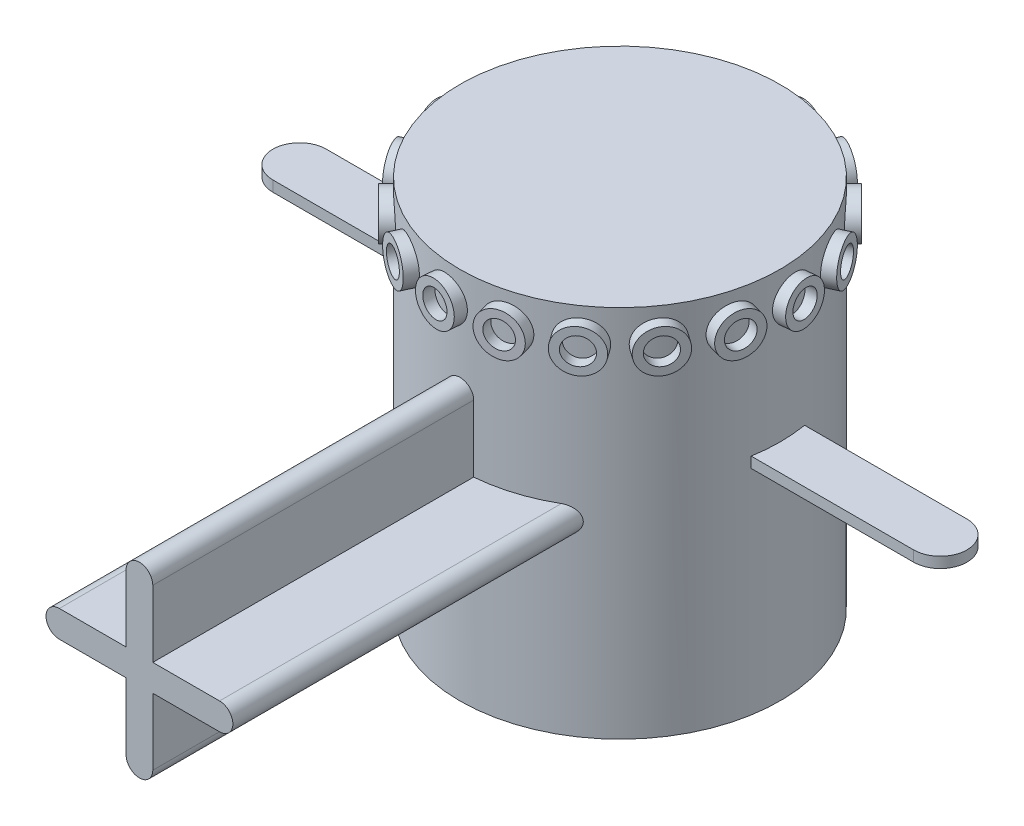
from build123d import *

# Parameters (mm, degrees)
SKETCH2_R           = 38.1
BOSS_EXTRUDE1_DEPTH = 88.9
BOSS_EXTRUDE2_DEPTH = 2.54
BOSS_EXTRUDE3_START = -7.153928
SKETCH4_W           = 6.35
SKETCH4_H           = 6.35
BOSS_EXTRUDE3_DEPTH = 83.353928
BOSS_EXTRUDE4_START = -0.340185
SKETCH6_R           = 5.08
SKETCH6_R_2         = 3.175
BOSS_EXTRUDE4_DEPTH = 2.880185
CIRPATTERN1_COUNT   = 18


with BuildPart() as part:
    # Sketch2 → Boss-Extrude1 (new body)
    with BuildSketch(Plane(origin=(0, 0, 0), x_dir=(1, 0, 0), z_dir=(0, 1, 0))):
        Circle(SKETCH2_R)
    extrude(amount=BOSS_EXTRUDE1_DEPTH)

    # Sketch3 → Boss-Extrude2 (add)
    with BuildSketch(Plane(origin=(0, 50.8, 0), x_dir=(1, 0, 0), z_dir=(0, 1, 0))):
        with BuildLine():
            Line((-76.2, 6.35), (76.2, 6.35))
            ThreePointArc((76.2, 6.35), (82.55, 0), (76.2, -6.35))
            Line((76.2, -6.35), (-76.2, -6.35))
            ThreePointArc((-76.2, -6.35), (-82.55, 0), (-76.2, 6.35))
        make_face()
    extrude(amount=BOSS_EXTRUDE2_DEPTH)

    # Sketch4 → Boss-Extrude3 (add)
    with BuildSketch(Plane.XY.offset(38.1).offset(BOSS_EXTRUDE3_START)):
        with BuildLine():
            Line((-3.175, 63.5), (-3.175, 47.625))
            Line((-3.175, 47.625), (3.175, 47.625))
            Line((3.175, 47.625), (3.175, 63.5))
            ThreePointArc((3.175, 63.5), (0, 66.675), (-3.175, 63.5))
        make_face()
        with BuildLine():
            Line((19.05, 47.625), (3.175, 47.625))
            Line((3.175, 47.625), (3.175, 41.275))
            Line((3.175, 41.275), (19.05, 41.275))
            ThreePointArc((19.05, 41.275), (22.225, 44.45), (19.05, 47.625))
        make_face()
        with BuildLine():
            Line((-3.175, 47.625), (-19.05, 47.625))
            ThreePointArc((-19.05, 47.625), (-22.225, 44.45), (-19.05, 41.275))
            Line((-19.05, 41.275), (-3.175, 41.275))
            Line((-3.175, 41.275), (-3.175, 47.625))
        make_face()
        with BuildLine():
            Line((3.175, 41.275), (-3.175, 41.275))
            Line((-3.175, 41.275), (-3.175, 25.4))
            ThreePointArc((-3.175, 25.4), (0, 22.225), (3.175, 25.4))
            Line((3.175, 25.4), (3.175, 41.275))
        make_face()
        with Locations((0, 44.45)):
            Rectangle(SKETCH4_W, SKETCH4_H)
    extrude(amount=BOSS_EXTRUDE3_DEPTH)

    # Sketch6 → Boss-Extrude4 (add)
    with BuildSketch(Plane(origin=(26.940768363, 88.9, -26.940768363), x_dir=(-0.707106781, 0, -0.707106781), z_dir=(0.707106781, 0, -0.707106781)).offset(BOSS_EXTRUDE4_START)):
        with Locations((0, -7.62)):
            Circle(SKETCH6_R)
        with Locations((0, -7.62)):
            Circle(SKETCH6_R_2, mode=Mode.SUBTRACT)
    boss_extrude4 = extrude(amount=BOSS_EXTRUDE4_DEPTH)

    # CirPattern1: Boss-Extrude4 ×18 about axis
    cirpattern1_axis = Axis((0, 0, 0), (0, 1, 0))
    for i in range(1, CIRPATTERN1_COUNT):
        add(boss_extrude4.rotate(cirpattern1_axis, i * 360 / CIRPATTERN1_COUNT))


solid = part.part
